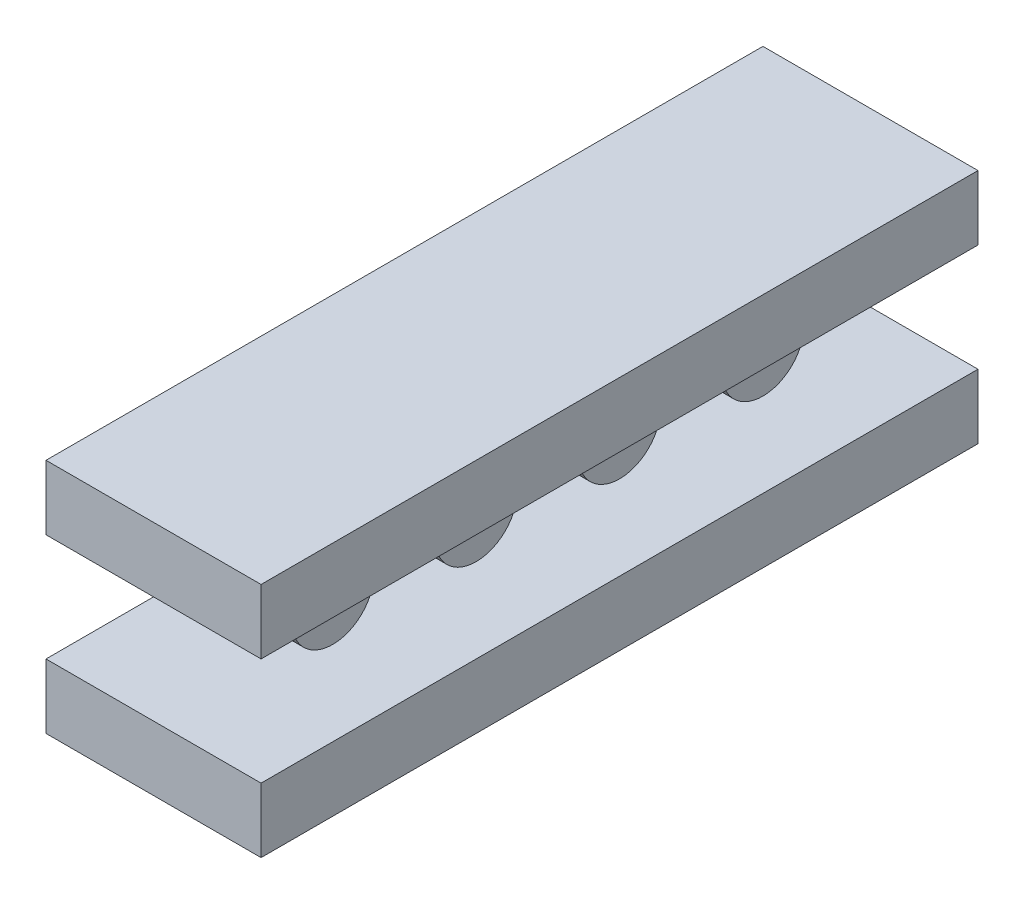
from build123d import *

# Parameters (mm, degrees)
SKETCH1_W             = 10
SKETCH1_H             = 0.9
BOSS_EXTRUDE1_DEPTH   = 3
BOSS_EXTRUDE1_2_DEPTH = 3
SKETCH2_R             = 0.575
BOSS_EXTRUDE2_DEPTH   = 2
BOSS_EXTRUDE2_2_DEPTH = 2
BOSS_EXTRUDE2_3_DEPTH = 2
BOSS_EXTRUDE2_4_DEPTH = 2


with BuildPart() as part:
    # Sketch1 → Boss-Extrude1 (new body)
    with BuildSketch(Plane(origin=(0, 0, 0), x_dir=(0, 0, -1), z_dir=(1, 0, 0))):
        with Locations((0, 1.2)):
            Rectangle(SKETCH1_W, SKETCH1_H)
    extrude(amount=BOSS_EXTRUDE1_DEPTH)


with BuildPart() as body_2:
    # Sketch1 → Boss-Extrude1 2 (new body)
    with BuildSketch(Plane(origin=(0, 0, 0), x_dir=(0, 0, -1), z_dir=(1, 0, 0))):
        with Locations((0, -1.2)):
            Rectangle(SKETCH1_W, SKETCH1_H)
    extrude(amount=BOSS_EXTRUDE1_2_DEPTH)


with BuildPart() as body_3:
    # Sketch2 → Boss-Extrude2 (new body)
    with BuildSketch(Plane.ZY):
        with Locations((-3, 0)):
            Circle(SKETCH2_R)
    extrude(amount=-BOSS_EXTRUDE2_DEPTH)


with BuildPart() as body_4:
    # Sketch2 → Boss-Extrude2 2 (new body)
    with BuildSketch(Plane.ZY):
        with Locations((-1, 0)):
            Circle(SKETCH2_R)
    extrude(amount=-BOSS_EXTRUDE2_2_DEPTH)


with BuildPart() as body_5:
    # Sketch2 → Boss-Extrude2 3 (new body)
    with BuildSketch(Plane.ZY):
        with Locations((1, 0)):
            Circle(SKETCH2_R)
    extrude(amount=-BOSS_EXTRUDE2_3_DEPTH)


with BuildPart() as body_6:
    # Sketch2 → Boss-Extrude2 4 (new body)
    with BuildSketch(Plane.ZY):
        with Locations((3, 0)):
            Circle(SKETCH2_R)
    extrude(amount=-BOSS_EXTRUDE2_4_DEPTH)


solid = Compound([part.part, body_2.part, body_3.part, body_4.part, body_5.part, body_6.part])
